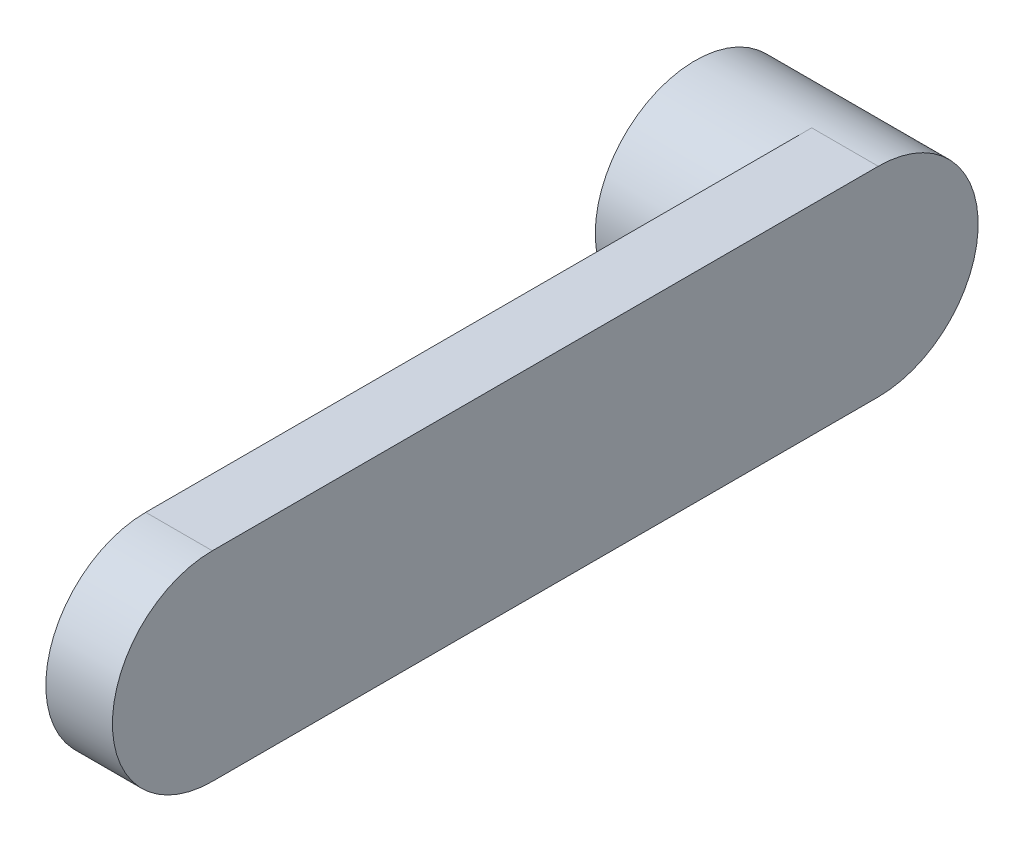
from build123d import *

# Parameters (mm, degrees)
EXTRUDE_1_DEPTH = 20
SKETCH_2_R      = 30
EXTRUDE_2_DEPTH = 35


with BuildPart() as part:
    # 草图1 → 凸台-拉伸1 (new body)
    with BuildSketch(Plane(origin=(0, 0, 0), x_dir=(0, 0, -1), z_dir=(1, 0, 0))):
        with BuildLine():
            Line((0, 30), (-200, 30))
            ThreePointArc((-200, 30), (-230, 0), (-200, -30))
            Line((-200, -30), (0, -30))
            ThreePointArc((0, -30), (30, 0), (0, 30))
        make_face()
    extrude(amount=EXTRUDE_1_DEPTH)

    # 草图2 → 凸台-拉伸2 (add)
    with BuildSketch(Plane.ZY):
        Circle(SKETCH_2_R)
    extrude(amount=EXTRUDE_2_DEPTH)


solid = part.part
